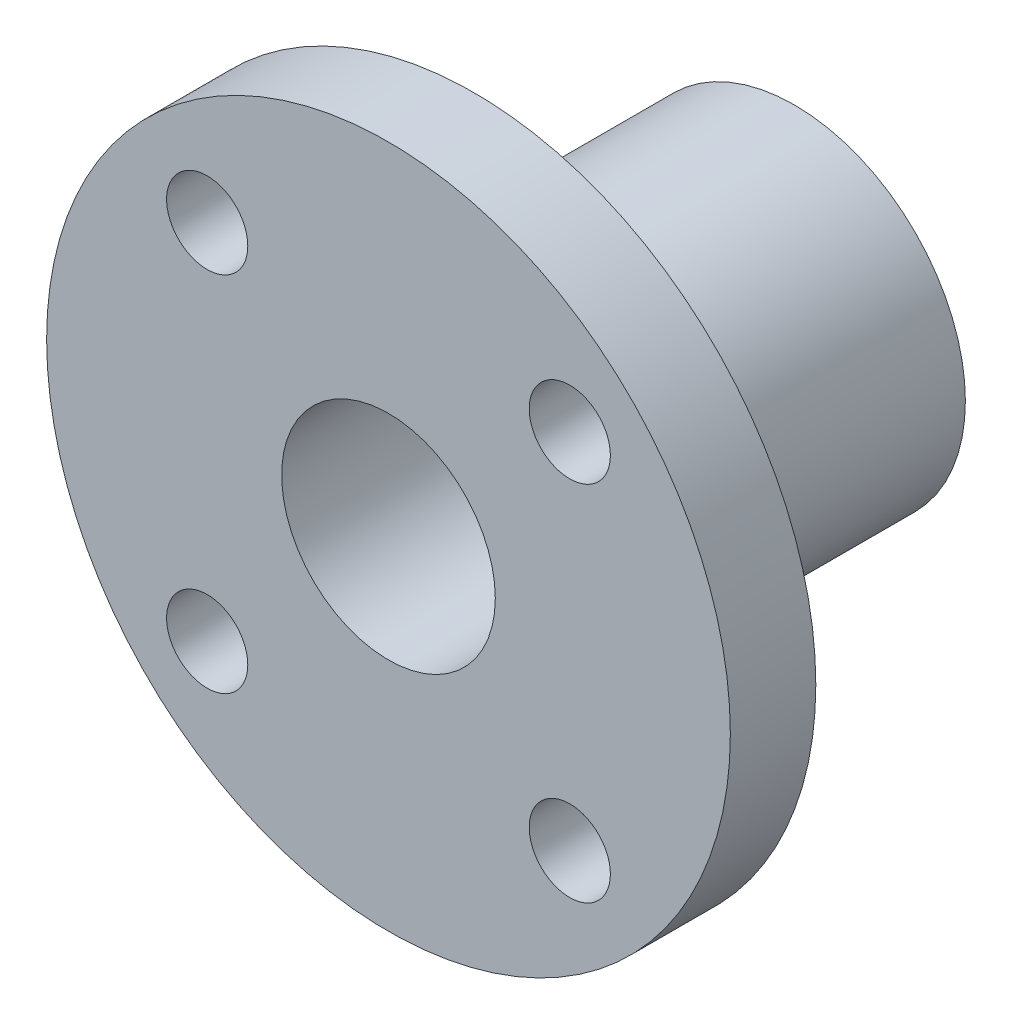
from build123d import *

# Parameters (mm, degrees)
SKETCH1_R      = 8
SKETCH1_R_2    = 5
EXTRUDE1_DEPTH = 15
SKETCH2_R      = 16
SKETCH2_R_2    = 5
SKETCH2_R_3    = 1.9
EXTRUDE2_DEPTH = 4


with BuildPart() as part:
    # Sketch1 → Extrude1 (new body)
    with BuildSketch(Plane.XY):
        Circle(SKETCH1_R)
        Circle(SKETCH1_R_2, mode=Mode.SUBTRACT)
    extrude(amount=EXTRUDE1_DEPTH)

    # Sketch2 → Extrude2 (add)
    with BuildSketch(Plane.XY.offset(15)):
        Circle(SKETCH2_R)
        Circle(SKETCH2_R_2, mode=Mode.SUBTRACT)
        with Locations((-8.485281374, 8.485281374)):
            Circle(SKETCH2_R_3, mode=Mode.SUBTRACT)
        with Locations((8.485281374, 8.485281374)):
            Circle(SKETCH2_R_3, mode=Mode.SUBTRACT)
        with Locations((-8.485281374, -8.485281374)):
            Circle(SKETCH2_R_3, mode=Mode.SUBTRACT)
        with Locations((8.485281374, -8.485281374)):
            Circle(SKETCH2_R_3, mode=Mode.SUBTRACT)
    extrude(amount=EXTRUDE2_DEPTH)


solid = part.part
